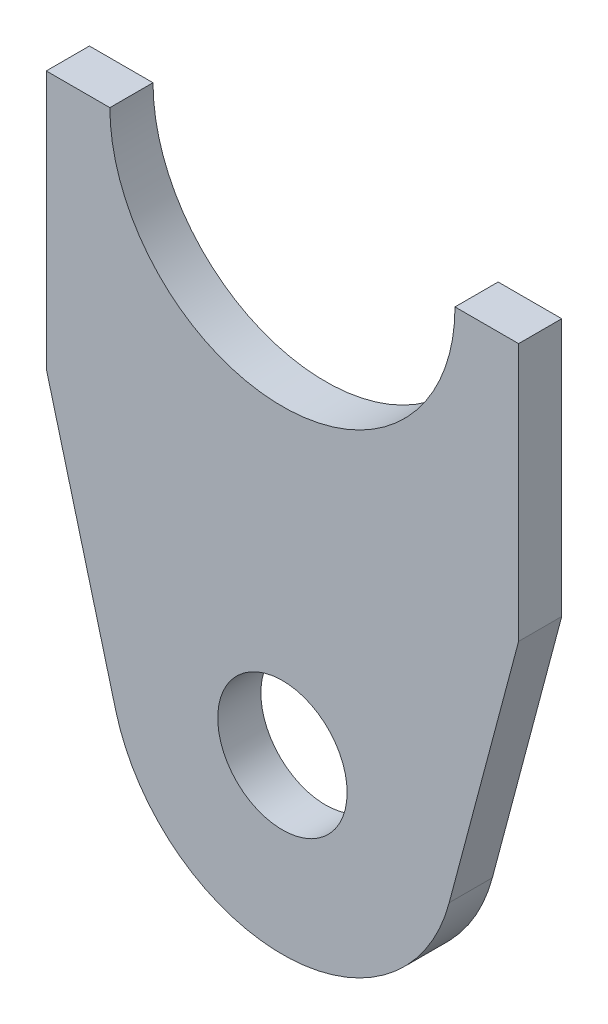
from build123d import *

# Parameters (mm, degrees)
SKETCH1_R           = 12.7
SKETCH1_R_2         = 4.7625
BOSS_EXTRUDE1_DEPTH = 3.175


with BuildPart() as part:
    # Sketch1 → Boss-Extrude1 (new body)
    with BuildSketch(Plane.XY):
        with BuildLine():
            Line((-12.70002942, 34.924992178), (-17.381139802, 34.924992178))
            Line((-17.381139802, 34.924992178), (-17.381139802, 15.948235146))
            Line((-17.381139802, 15.948235146), (-12.273648862, -3.263057403))
            ThreePointArc((-12.273648862, -3.263057403), (-1.645396526, 12.59296114), (12.7, 0))
            ThreePointArc((12.7, 0), (12.592963493, -1.645378514), (12.273658196, -3.263022292))
            Line((12.273658196, -3.263022292), (17.381080961, 15.948235146))
            Line((17.381080961, 15.948235146), (17.381080961, 34.924992178))
            Line((17.381080961, 34.924992178), (12.69997058, 34.924992178))
            ThreePointArc((12.69997058, 34.924992178), (-2.942e-05, 22.224992178), (-12.70002942, 34.924992178))
        make_face()
        Circle(SKETCH1_R)
        Circle(SKETCH1_R_2, mode=Mode.SUBTRACT)
    extrude(amount=BOSS_EXTRUDE1_DEPTH)


solid = part.part
